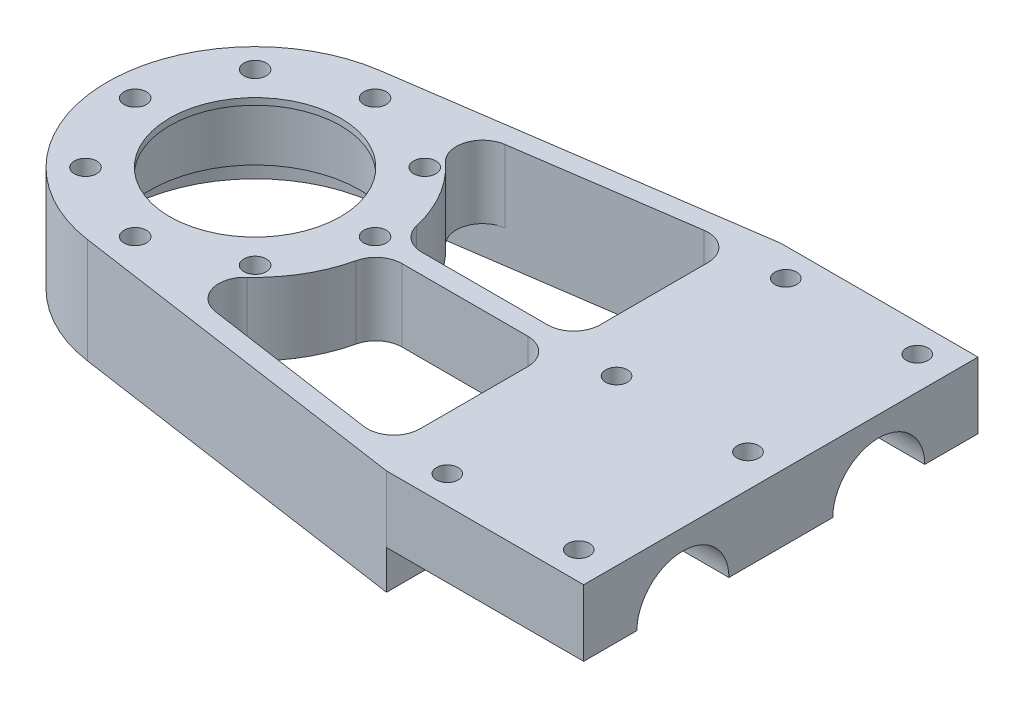
from build123d import *

# Parameters (mm, degrees)
EXTRUDE_1_DEPTH      = 16
SKETCH_2_R           = 16
CUT_EXTRUDE_1_DEPTH  = 15
SKETCH_3_R           = 13
CUT_EXTRUDE_2_DEPTH  = 120.713198938
SKETCH_4_R           = 20.5
CUT_EXTRUDE_3_DEPTH  = 5
HOLE_WIZARD_M32_D    = 3.4
CUT_EXTRUDE_8_DEPTH  = 30
CUT_EXTRUDE_11_DEPTH = 120.842605112
EXTRUDE_2_DEPTH      = 11
FILLET_1_R           = 4
M4X0_71_D            = 3.3


with BuildPart() as part:
    # Эскиз1 → Бобышка-Вытянуть1 (new body)
    with BuildSketch(Plane(origin=(0, 0, 0), x_dir=(1, 0, 0), z_dir=(0, 1, 0))):
        with BuildLine():
            Line((0, 0), (0, 60))
            Line((0, 60), (-30, 60))
            Line((-30, 60), (-83.234756238, 52.266260397))
            ThreePointArc((-83.234756238, 52.266260397), (-102.5, 30), (-83.234756238, 7.733739603))
            Line((-83.234756238, 7.733739603), (-30, 0))
            Line((-30, 0), (0, 0))
        make_face()
    extrude(amount=EXTRUDE_1_DEPTH)

    # Эскиз2 → Вырез-Вытянуть1 (cut)
    with BuildSketch(Plane.XZ):
        with Locations(Location((-80, -30, 0), (0, 0, 270))):
            Circle(SKETCH_2_R)
    extrude(amount=-CUT_EXTRUDE_1_DEPTH, mode=Mode.SUBTRACT)

    # Эскиз3 → Вырез-Вытянуть2 (cut, through all)
    with BuildSketch(Plane.XZ.offset(-15)):
        with Locations(Location((-80, -30, 0), (0, 0, 270))):
            Circle(SKETCH_3_R)
    extrude(amount=-CUT_EXTRUDE_2_DEPTH, mode=Mode.SUBTRACT)

    # Эскиз4 → Вырез-Вытянуть3 (cut)
    with BuildSketch(Plane.XZ):
        with Locations(Location((-80, -30, 0), (0, 0, 270))):
            Circle(SKETCH_4_R)
    extrude(amount=-CUT_EXTRUDE_3_DEPTH, mode=Mode.SUBTRACT)

    # Отверстие с зазором M32 (through all)
    with Locations(Plane(origin=(0, 5, 0), x_dir=(-1, 0, 0), z_dir=(0, -1, 0))):
        with Locations((92.904698757, 17.095301243), (67.095301243, 17.095301243), (67.095301243, 42.904698757), (92.904698757, 42.904698757), (80, 11.75), (61.75, 30), (80, 48.25), (98.25, 30)):
            Hole(HOLE_WIZARD_M32_D / 2)

    # Эскиз8 → Вырез-Вытянуть8 (cut)
    with BuildSketch(Plane(origin=(0, 0, 0), x_dir=(0, 0, -1), z_dir=(1, 0, 0))):
        with BuildLine():
            Line((37.9, 5.9), (22.1, 5.9))
            ThreePointArc((22.1, 5.9), (15.1, 12.9), (8.1, 5.9))
            Line((8.1, 5.9), (0, 5.9))
            Line((0, 5.9), (0, 0))
            Line((0, 0), (60, 0))
            Line((60, 0), (60, 5.9))
            Line((60, 5.9), (51.9, 5.9))
            ThreePointArc((51.9, 5.9), (44.9, 12.9), (37.9, 5.9))
        make_face()
    extrude(amount=-CUT_EXTRUDE_8_DEPTH, mode=Mode.SUBTRACT)

    # Эскиз14 → Вырез-Вытянуть11 (cut, through all)
    with BuildSketch(Plane.XZ):
        with BuildLine():
            Line((-33, -56.53267916), (-76.544602266, -50.206687668))
            ThreePointArc((-76.544602266, -50.206687668), (-59.5, -30), (-76.544602266, -9.793312332))
            Line((-76.544602266, -9.793312332), (-33, -3.46732084))
            Line((-33, -3.46732084), (-33, -56.53267916))
        make_face()
    extrude(amount=-CUT_EXTRUDE_11_DEPTH, mode=Mode.SUBTRACT)

    # Эскиз15 → Бобышка-Вытянуть2 (add, through all)
    with BuildSketch(Plane.XZ.offset(-5)):
        with BuildLine():
            Line((-59.5549517, -31.5), (-33, -31.5))
            Line((-33, -31.5), (-33, -28.5))
            Line((-33, -28.5), (-59.5549517, -28.5))
            ThreePointArc((-59.5549517, -28.5), (-59.5, -30), (-59.5549517, -31.5))
        make_face()
    extrude(amount=-EXTRUDE_2_DEPTH)

    # Скругление1
    fillet_1_edges = [part.edges().sort_by_distance(p)[0] for p in [
        (-76.544602266, 10.5, -50.206687668),
        (-76.544602266, 10.5, -9.793312332),
        (-33, 8, -3.46732084),
        (-33, 8, -56.53267916),
        (-33, 10.5, -28.5),
        (-33, 10.5, -31.5),
        (-59.5549517, 10.5, -31.5),
        (-59.5549517, 10.5, -28.5),
    ]]
    fillet(fillet_1_edges, radius=FILLET_1_R)

    # Отверстие обработанное метчиком M4x0.71 (through all)
    with Locations(Plane(origin=(-72.539630463, 5.9, -28.004308474), x_dir=(-0.7071067811865468, 0, 0.7071067811865482), z_dir=(0, -1, 0))):
        with Locations((-67.376897326, -28.138564072), (-53.234761703, -13.996428448), (-35.026762087, -32.204428064), (-49.168897711, -46.346563688), (-30.960898095, -64.554563303), (-16.818762471, -50.412427679)):
            Hole(M4X0_71_D / 2)


solid = part.part
